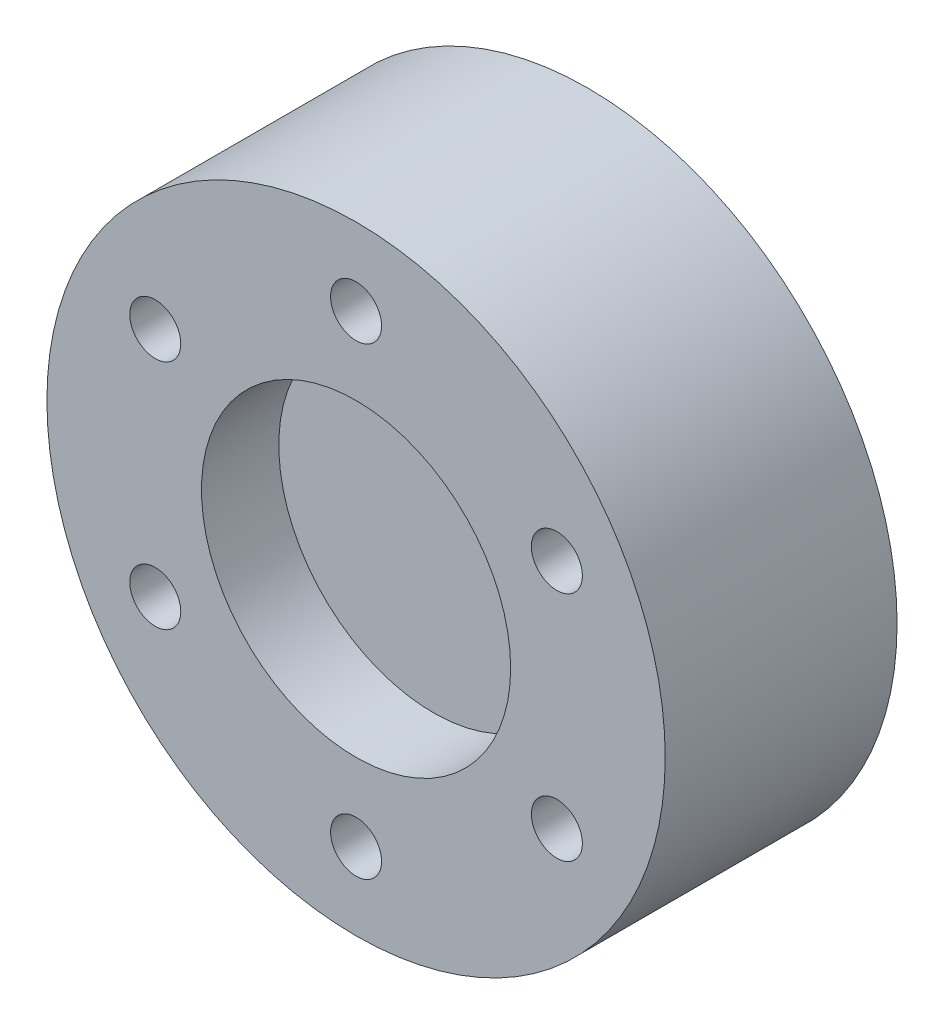
from build123d import *

# Parameters (mm, degrees)
SKETCH1_R           = 20
BOSS_EXTRUDE1_DEPTH = 15
SKETCH2_R           = 10
CUT_EXTRUDE1_DEPTH  = 5
CIRPATTERN1_COUNT   = 6
SKETCH5_R           = 17.5
CUT_EXTRUDE3_DEPTH  = 3


with BuildPart() as part:
    # Sketch1 → Boss-Extrude1 (new body)
    with BuildSketch(Plane.XY):
        Circle(SKETCH1_R)
    extrude(amount=BOSS_EXTRUDE1_DEPTH)

    # Sketch2 → Cut-Extrude1 (cut)
    with BuildSketch(Plane.XY.offset(15)):
        Circle(SKETCH2_R)
    extrude(amount=-CUT_EXTRUDE1_DEPTH, mode=Mode.SUBTRACT)

    # Sketch4 → M4x0.7 Tapped Hole1 (revolve, cut)
    with BuildSketch(Plane(origin=(0, 15, 15), x_dir=(0, -1, 0), z_dir=(1, 0, 0))):
        Polygon((0, 0), (0, 11.091420021), (1.65, 10.1), (1.65, 0), align=None)
    m4x0_7_tapped_hole1 = revolve(axis=Axis((0, 15, 21.35), (0, 0, -1)), mode=Mode.SUBTRACT)

    # CirPattern1: M4x0.7 Tapped Hole1 ×6 about axis
    cirpattern1_axis = Axis((0, 0, 0), (0, 0, 1))
    for i in range(1, CIRPATTERN1_COUNT):
        add(m4x0_7_tapped_hole1.rotate(cirpattern1_axis, i * 360 / CIRPATTERN1_COUNT), mode=Mode.SUBTRACT)

    # Sketch5 → Cut-Extrude3 (cut)
    with BuildSketch(Plane(origin=(0, 0, 0), x_dir=(-1, 0, 0), z_dir=(0, 0, -1))):
        Circle(SKETCH5_R)
    extrude(amount=-CUT_EXTRUDE3_DEPTH, mode=Mode.SUBTRACT)


solid = part.part
